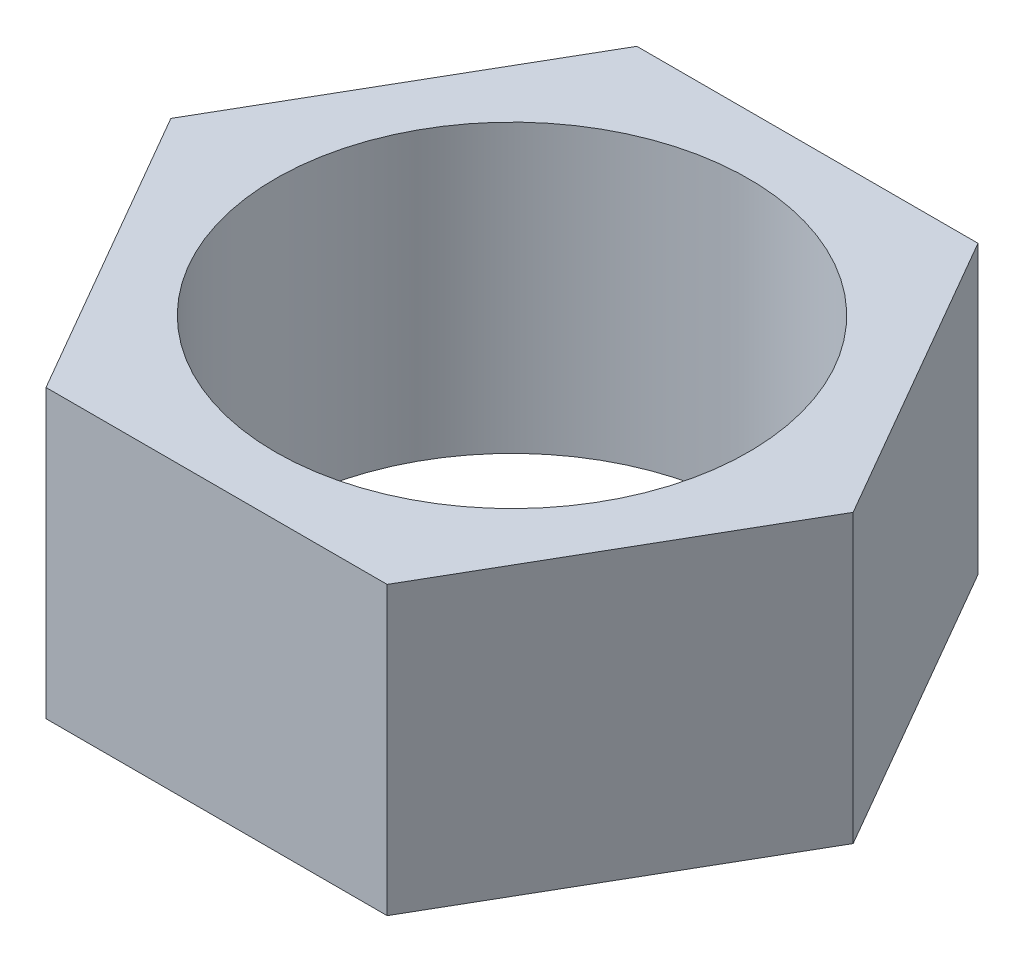
from build123d import *

# Parameters (mm, degrees)
CROQUIS1_R              = 1.65
SALIENTE_EXTRUIR1_DEPTH = 2


with BuildPart() as part:
    # Croquis1 → Saliente-Extruir1 (new body)
    with BuildSketch(Plane(origin=(0, 0, 0), x_dir=(1, 0, 0), z_dir=(0, 1, 0))):
        Polygon((2.378166231, 0), (1.189083115, 2.05955237), (-1.189083115, 2.05955237), (-2.378166231, 0), (-1.189083115, -2.05955237), (1.189083115, -2.05955237), align=None)
        Circle(CROQUIS1_R, mode=Mode.SUBTRACT)
    extrude(amount=SALIENTE_EXTRUIR1_DEPTH)


solid = part.part
